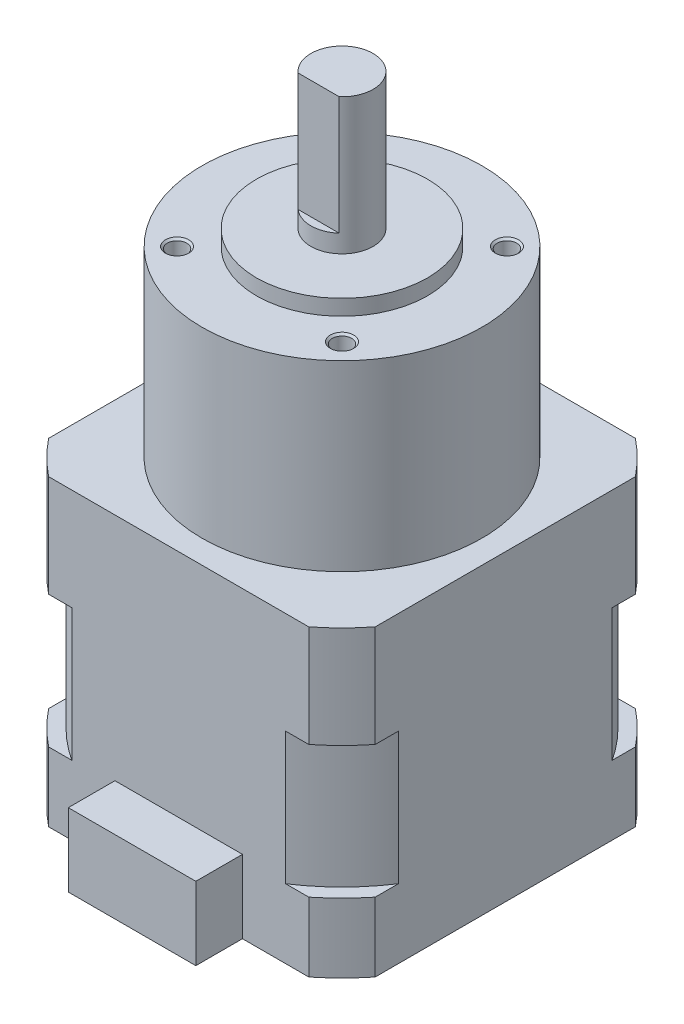
from build123d import *

# Parameters (mm, degrees)
SZKIC1_W                         = 42
SZKIC1_H                         = 42
DODANIE_WYCI_GNI_CIE1_DEPTH      = 39
SZKIC1_3_R                       = 18
DODANIE_WYCI_GNI_CIE2_DEPTH      = 62.5
SZKIC1_4_R                       = 11
DODANIE_WYCI_GNI_CIE3_DEPTH      = 64.5
SZKIC1_5_R                       = 4
DODANIE_WYCI_GNI_CIE4_DEPTH      = 66.8
DODANIE_WYCI_GNI_CIE5_DEPTH      = 82
SZKIC2_OUTSIDE_W                 = 64.25
SZKIC2_OUTSIDE_H                 = 64.25
SZKIC2_OUTSIDE_R                 = 26.85
WYTNIJ_WYCI_GNI_CIE2_DEPTH       = 83
WYTNIJ_WYCI_GNI_CIE3_START       = 8.9
SZKIC3_OUTSIDE_W                 = 64.25
SZKIC3_OUTSIDE_H                 = 64.25
SZKIC3_OUTSIDE_R                 = 25.1
WYTNIJ_WYCI_GNI_CIE3_DEPTH       = 17
SZKIC4_R                         = 4.65
WYTNIJ_WYCI_GNI_CIE5_DEPTH       = 4
OTW_R_GWINTOWANY_M31_D           = 2.5
OTW_R_GWINTOWANY_M31_DEPTH       = 9
OTW_R_GWINTOWANY_M31_CSINK_D     = 3
OTW_R_GWINTOWANY_M31_CSINK_ANGLE = 90
OTW_R_GWINTOWANY_M31_TIP         = 0.751075774
DODANIE_WYCI_GNI_CIE6_START      = 21
SZKIC18_W                        = 16.4
SZKIC18_H                        = 9.4
DODANIE_WYCI_GNI_CIE6_DEPTH      = 6


with BuildPart() as part:
    # Szkic1 → Dodanie-wyci_gni_cie1 (new body)
    with BuildSketch(Plane(origin=(0, 0, 0), x_dir=(1, 0, 0), z_dir=(0, 1, 0))):
        Rectangle(SZKIC1_W, SZKIC1_H)
    extrude(amount=DODANIE_WYCI_GNI_CIE1_DEPTH)

    # Szkic1_3 → Dodanie-wyci_gni_cie2 (add)
    with BuildSketch(Plane(origin=(0, 0, 0), x_dir=(1, 0, 0), z_dir=(0, 1, 0))):
        Circle(SZKIC1_3_R)
    extrude(amount=DODANIE_WYCI_GNI_CIE2_DEPTH)

    # Szkic1_4 → Dodanie-wyci_gni_cie3 (add)
    with BuildSketch(Plane(origin=(0, 0, 0), x_dir=(1, 0, 0), z_dir=(0, 1, 0))):
        Circle(SZKIC1_4_R)
    extrude(amount=DODANIE_WYCI_GNI_CIE3_DEPTH)

    # Szkic1_5 → Dodanie-wyci_gni_cie4 (add)
    with BuildSketch(Plane(origin=(0, 0, 0), x_dir=(1, 0, 0), z_dir=(0, 1, 0))):
        Circle(SZKIC1_5_R)
    extrude(amount=DODANIE_WYCI_GNI_CIE4_DEPTH)

    # Szkic1_6 → Dodanie-wyci_gni_cie5 (add)
    with BuildSketch(Plane(origin=(0, 0, 0), x_dir=(1, 0, 0), z_dir=(0, 1, 0))):
        with BuildLine():
            Line((-2.645751311, -3), (2.645751311, -3))
            ThreePointArc((2.645751311, -3), (0, 4), (-2.645751311, -3))
        make_face()
    extrude(amount=DODANIE_WYCI_GNI_CIE5_DEPTH)

    # Szkic2 outside → Wytnij-wyci_gni_cie2 (cut, through all)
    with BuildSketch(Plane(origin=(0, 0, 0), x_dir=(1, 0, 0), z_dir=(0, 1, 0))):
        Rectangle(SZKIC2_OUTSIDE_W, SZKIC2_OUTSIDE_H)
        Circle(SZKIC2_OUTSIDE_R, mode=Mode.SUBTRACT)
    extrude(amount=WYTNIJ_WYCI_GNI_CIE2_DEPTH, mode=Mode.SUBTRACT)

    # Szkic3 outside → Wytnij-wyci_gni_cie3 (cut)
    with BuildSketch(Plane(origin=(0, 0, 0), x_dir=(1, 0, 0), z_dir=(0, 1, 0)).offset(WYTNIJ_WYCI_GNI_CIE3_START)):
        Rectangle(SZKIC3_OUTSIDE_W, SZKIC3_OUTSIDE_H)
        Circle(SZKIC3_OUTSIDE_R, mode=Mode.SUBTRACT)
    extrude(amount=WYTNIJ_WYCI_GNI_CIE3_DEPTH, mode=Mode.SUBTRACT)

    # Szkic4 → Wytnij-wyci_gni_cie5 (cut)
    with BuildSketch(Plane(origin=(0, 0, 0), x_dir=(1, 0, 0), z_dir=(0, 1, 0))):
        Circle(SZKIC4_R)
    extrude(amount=WYTNIJ_WYCI_GNI_CIE5_DEPTH, mode=Mode.SUBTRACT)

    # Otw_r gwintowany M31
    with Locations(Plane(origin=(0, 62.5, 0), x_dir=(1, 0, 0), z_dir=(0, 1, 0))):
        with Locations((-10.606601718, 10.606601718), (10.606601718, 10.606601718), (10.606601718, -10.606601718), (-10.606601718, -10.606601718)):
            CounterSinkHole(OTW_R_GWINTOWANY_M31_D / 2, OTW_R_GWINTOWANY_M31_CSINK_D / 2, depth=OTW_R_GWINTOWANY_M31_DEPTH, counter_sink_angle=OTW_R_GWINTOWANY_M31_CSINK_ANGLE)
            with Locations((0, 0, -(OTW_R_GWINTOWANY_M31_DEPTH + OTW_R_GWINTOWANY_M31_TIP / 2))):  # 118° drill point
                Cone(0, OTW_R_GWINTOWANY_M31_D / 2, OTW_R_GWINTOWANY_M31_TIP, mode=Mode.SUBTRACT)

    # Szkic18 → Dodanie-wyci_gni_cie6 (add)
    with BuildSketch(Plane.XY.offset(DODANIE_WYCI_GNI_CIE6_START)):
        with Locations((0, 4.7)):
            Rectangle(SZKIC18_W, SZKIC18_H)
    extrude(amount=DODANIE_WYCI_GNI_CIE6_DEPTH)


solid = part.part
